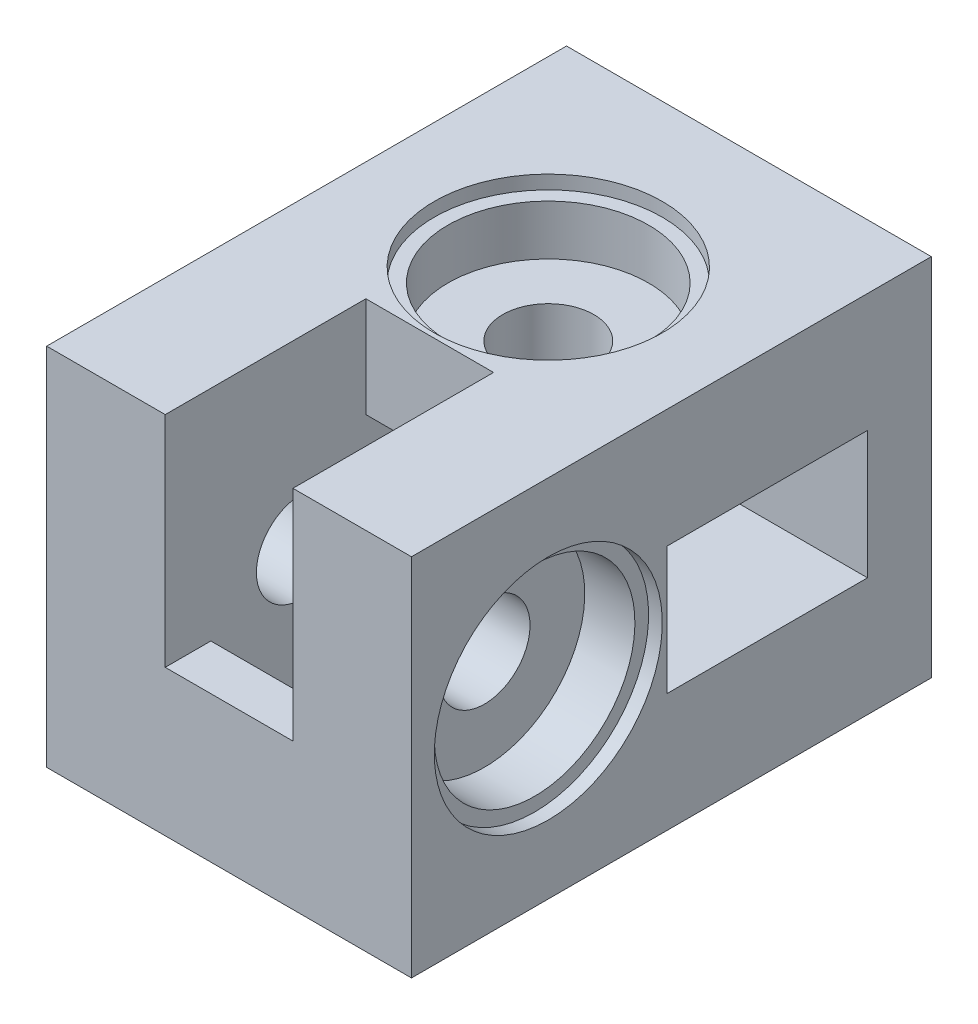
from build123d import *

# Parameters (mm, degrees)
ESQUISSE1_W              = 40
ESQUISSE1_H              = 40
BOSS_EXTRU_1_DEPTH       = 50
ESQUISSE2_R              = 5
ENL_V_MAT_EXTRU_1_DEPTH  = 41
ESQUISSE3_R              = 5
ENL_V_MAT_EXTRU_2_DEPTH  = 41
ESQUISSE4_W              = 20
ESQUISSE4_H              = 14
ENL_V_MAT_EXTRU_3_DEPTH  = 29
ESQUISSE5_W              = 14
ESQUISSE5_H              = 20
ENL_V_MAT_EXTRU_4_DEPTH  = 29
ESQUISSE6_W              = 22
ESQUISSE6_H              = 14
ENL_V_MAT_EXTRU_5_DEPTH  = 24
ESQUISSE7_W              = 14
ESQUISSE7_H              = 22
ENL_V_MAT_EXTRU_6_DEPTH  = 24
ESQUISSE8_R              = 11
ENL_V_MAT_EXTRU_7_DEPTH  = 7
ESQUISSE9_R              = 12.5
ENL_V_MAT_EXTRU_8_DEPTH  = 1.5
ESQUISSE10_R             = 11
ENL_V_MAT_EXTRU_9_DEPTH  = 7
ESQUISSE11_R             = 12.5
ENL_V_MAT_EXTRU_10_DEPTH = 1.5
ESQUISSE12_W             = 40
ESQUISSE12_H             = 40
BOSS_EXTRU_2_DEPTH       = 7
ESQUISSE13_R             = 2.25
ENL_V_MAT_EXTRU_11_DEPTH = 15
ESQUISSE14_W             = 3.5
ESQUISSE14_H             = 7.5
ENL_V_MAT_EXTRU_12_DEPTH = 12
ESQUISSE15_W             = 7.5
ESQUISSE15_H             = 3.5
ENL_V_MAT_EXTRU_13_DEPTH = 12


with BuildPart() as part:
    # Esquisse1 → Boss.-Extru.1 (new body)
    with BuildSketch(Plane.XY):
        with Locations((-20, 20)):
            Rectangle(ESQUISSE1_W, ESQUISSE1_H)
    extrude(amount=BOSS_EXTRU_1_DEPTH)

    # Esquisse2 → Enlèv. mat.-Extru.1 (cut, through all)
    with BuildSketch(Plane(origin=(0, 40, 0), x_dir=(1, 0, 0), z_dir=(0, 1, 0))):
        with Locations(Location((-20, -15, 0), (0, 0, 270))):  # turned: the seam where the file's is
            Circle(ESQUISSE2_R)
    extrude(amount=-ENL_V_MAT_EXTRU_1_DEPTH, mode=Mode.SUBTRACT)

    # Esquisse3 → Enlèv. mat.-Extru.2 (cut, through all)
    with BuildSketch(Plane.ZY.offset(40)):
        with Locations((35, 20)):
            Circle(ESQUISSE3_R)
    extrude(amount=-ENL_V_MAT_EXTRU_2_DEPTH, mode=Mode.SUBTRACT)

    # Esquisse4 → Enlèv. mat.-Extru.3 (cut)
    with BuildSketch(Plane.ZY.offset(40)):
        with Locations((15, 20)):
            Rectangle(ESQUISSE4_W, ESQUISSE4_H)
    extrude(amount=-ENL_V_MAT_EXTRU_3_DEPTH, mode=Mode.SUBTRACT)

    # Esquisse5 → Enlèv. mat.-Extru.4 (cut)
    with BuildSketch(Plane.XZ):
        with Locations((-20, 35)):
            Rectangle(ESQUISSE5_W, ESQUISSE5_H)
    extrude(amount=-ENL_V_MAT_EXTRU_4_DEPTH, mode=Mode.SUBTRACT)

    # Esquisse6 → Enlèv. mat.-Extru.5 (cut)
    with BuildSketch(Plane(origin=(0, 0, 0), x_dir=(0, 0, -1), z_dir=(1, 0, 0))):
        with Locations((-11, 20)):
            Rectangle(ESQUISSE6_W, ESQUISSE6_H)
    extrude(amount=-ENL_V_MAT_EXTRU_5_DEPTH, mode=Mode.SUBTRACT)

    # Esquisse7 → Enlèv. mat.-Extru.6 (cut)
    with BuildSketch(Plane(origin=(0, 40, 0), x_dir=(1, 0, 0), z_dir=(0, 1, 0))):
        with Locations((-20, -39)):
            Rectangle(ESQUISSE7_W, ESQUISSE7_H)
    extrude(amount=-ENL_V_MAT_EXTRU_6_DEPTH, mode=Mode.SUBTRACT)

    # Esquisse8 → Enlèv. mat.-Extru.7 (cut)
    with BuildSketch(Plane(origin=(0, 0, 0), x_dir=(0, 0, -1), z_dir=(1, 0, 0))):
        with Locations(Location((-35, 20, 0), (0, 0, 90))):  # turned: the seam where the file's is
            Circle(ESQUISSE8_R)
    extrude(amount=-ENL_V_MAT_EXTRU_7_DEPTH, mode=Mode.SUBTRACT)

    # Esquisse9 → Enlèv. mat.-Extru.8 (cut)
    with BuildSketch(Plane(origin=(0, 0, 0), x_dir=(0, 0, -1), z_dir=(1, 0, 0))):
        with Locations(Location((-35, 20, 0), (0, 0, 90))):  # turned: the seam where the file's is
            Circle(ESQUISSE9_R)
    extrude(amount=-ENL_V_MAT_EXTRU_8_DEPTH, mode=Mode.SUBTRACT)

    # Esquisse10 → Enlèv. mat.-Extru.9 (cut)
    with BuildSketch(Plane(origin=(0, 40, 0), x_dir=(1, 0, 0), z_dir=(0, 1, 0))):
        with Locations(Location((-20, -15, 0), (0, 0, 270))):  # turned: the seam where the file's is
            Circle(ESQUISSE10_R)
    extrude(amount=-ENL_V_MAT_EXTRU_9_DEPTH, mode=Mode.SUBTRACT)

    # Esquisse11 → Enlèv. mat.-Extru.10 (cut)
    with BuildSketch(Plane(origin=(0, 40, 0), x_dir=(1, 0, 0), z_dir=(0, 1, 0))):
        with Locations(Location((-20, -15, 0), (0, 0, 270))):  # turned: the seam where the file's is
            Circle(ESQUISSE11_R)
    extrude(amount=-ENL_V_MAT_EXTRU_10_DEPTH, mode=Mode.SUBTRACT)

    # Esquisse12 → Boss.-Extru.2 (add)
    with BuildSketch(Plane(origin=(0, 0, 0), x_dir=(-1, 0, 0), z_dir=(0, 0, -1))):
        with Locations((20, 20)):
            Rectangle(ESQUISSE12_W, ESQUISSE12_H)
    extrude(amount=BOSS_EXTRU_2_DEPTH)

    # Esquisse13 → Enlèv. mat.-Extru.11 (cut)
    with BuildSketch(Plane(origin=(0, 0, -7), x_dir=(-1, 0, 0), z_dir=(0, 0, -1))):
        with Locations((10, 7.5)):
            Circle(ESQUISSE13_R)
        with Locations((32.5, 30)):
            Circle(ESQUISSE13_R)
    extrude(amount=-ENL_V_MAT_EXTRU_11_DEPTH, mode=Mode.SUBTRACT)

    # Esquisse14 → Enlèv. mat.-Extru.12 (cut)
    with BuildSketch(Plane.ZY.offset(40)):
        with Locations((-1.25, 30)):
            Rectangle(ESQUISSE14_W, ESQUISSE14_H)
    extrude(amount=-ENL_V_MAT_EXTRU_12_DEPTH, mode=Mode.SUBTRACT)

    # Esquisse15 → Enlèv. mat.-Extru.13 (cut)
    with BuildSketch(Plane.XZ):
        with Locations((-10, -1.25)):
            Rectangle(ESQUISSE15_W, ESQUISSE15_H)
    extrude(amount=-ENL_V_MAT_EXTRU_13_DEPTH, mode=Mode.SUBTRACT)


solid = part.part
